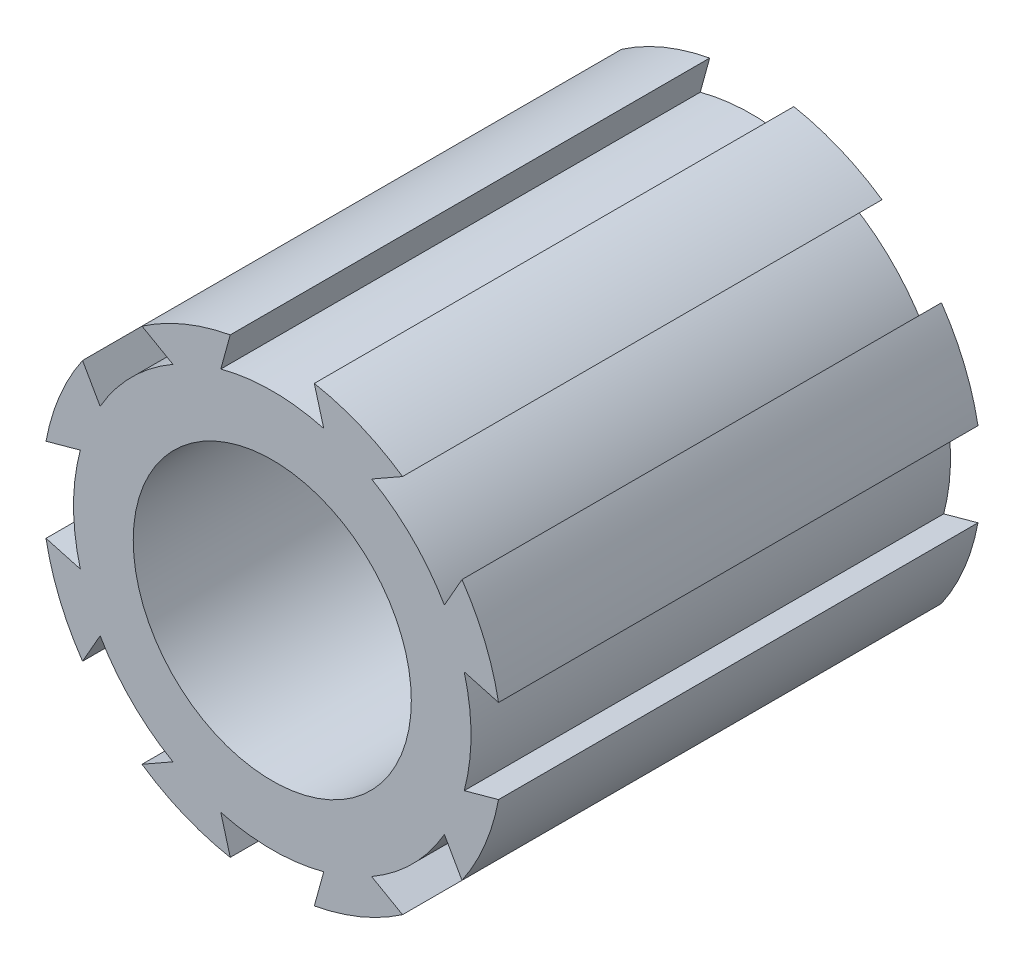
from build123d import *

# Parameters (mm, degrees)
ESQUISSE5_R                  = 24
ESQUISSE5_R_2                = 14.5
BOSS_EXTRU_2_DEPTH           = 50
ENL_V_MAT_EXTRU_4_DEPTH      = 61.431779719
ENL_V_MAT_EXTRU_4_DEPTH_BACK = 16


with BuildPart() as part:
    # Esquisse5 → Boss.-Extru.2 (new body)
    with BuildSketch(Plane.XY):
        Circle(ESQUISSE5_R)
        Circle(ESQUISSE5_R_2, mode=Mode.SUBTRACT)
    extrude(amount=BOSS_EXTRU_2_DEPTH)

    # Esquisse6 → Enlèv. mat.-Extru.4 (cut, two sides: drawn at the far end of the back side and taken through both)
    with BuildSketch(Plane.XY.offset(-ENL_V_MAT_EXTRU_4_DEPTH_BACK)):
        with BuildLine():
            Line((-4.384096163, 23.596179793), (-5.367769198, 20.017709679))
            ThreePointArc((-5.367769198, 20.017709679), (0, 20.724904028), (5.367769198, 20.017709679))
            Line((5.367769198, 20.017709679), (4.384096163, 23.596179793))
            ThreePointArc((4.384096163, 23.596179793), (0, 24), (-4.384096163, 23.596179793))
        make_face()
        with BuildLine():
            Line((19.785042868, 13.584994616), (17.950244258, 10.359072259))
            ThreePointArc((17.950244258, 10.359072259), (14.654720178, 14.654720178), (10.359072259, 17.950244258))
            Line((10.359072259, 17.950244258), (13.584994616, 19.785042868))
            ThreePointArc((13.584994616, 19.785042868), (16.970562748, 16.970562748), (19.785042868, 13.584994616))
        make_face()
        with BuildLine():
            Line((23.596179793, -4.384096163), (20.017709679, -5.367769198))
            ThreePointArc((20.017709679, -5.367769198), (20.724904028, 0), (20.017709679, 5.367769198))
            Line((20.017709679, 5.367769198), (23.596179793, 4.384096163))
            ThreePointArc((23.596179793, 4.384096163), (24, 0), (23.596179793, -4.384096163))
        make_face()
        with BuildLine():
            Line((13.584994616, -19.785042868), (10.359072259, -17.950244258))
            ThreePointArc((10.359072259, -17.950244258), (14.654720178, -14.654720178), (17.950244258, -10.359072259))
            Line((17.950244258, -10.359072259), (19.785042868, -13.584994616))
            ThreePointArc((19.785042868, -13.584994616), (16.970562748, -16.970562748), (13.584994616, -19.785042868))
        make_face()
        with BuildLine():
            Line((-4.384096163, -23.596179793), (-5.367769198, -20.017709679))
            ThreePointArc((-5.367769198, -20.017709679), (0, -20.724904028), (5.367769198, -20.017709679))
            Line((5.367769198, -20.017709679), (4.384096163, -23.596179793))
            ThreePointArc((4.384096163, -23.596179793), (0, -24), (-4.384096163, -23.596179793))
        make_face()
        with BuildLine():
            Line((-19.785042868, -13.584994616), (-17.950244258, -10.359072259))
            ThreePointArc((-17.950244258, -10.359072259), (-14.654720178, -14.654720178), (-10.359072259, -17.950244258))
            Line((-10.359072259, -17.950244258), (-13.584994616, -19.785042868))
            ThreePointArc((-13.584994616, -19.785042868), (-16.970562748, -16.970562748), (-19.785042868, -13.584994616))
        make_face()
        with BuildLine():
            Line((-23.596179793, 4.384096163), (-20.017709679, 5.367769198))
            ThreePointArc((-20.017709679, 5.367769198), (-20.724904028, 0), (-20.017709679, -5.367769198))
            Line((-20.017709679, -5.367769198), (-23.596179793, -4.384096163))
            ThreePointArc((-23.596179793, -4.384096163), (-24, 0), (-23.596179793, 4.384096163))
        make_face()
        with BuildLine():
            Line((-13.584994616, 19.785042868), (-10.359072259, 17.950244258))
            ThreePointArc((-10.359072259, 17.950244258), (-14.654720178, 14.654720178), (-17.950244258, 10.359072259))
            Line((-17.950244258, 10.359072259), (-19.785042868, 13.584994616))
            ThreePointArc((-19.785042868, 13.584994616), (-16.970562748, 16.970562748), (-13.584994616, 19.785042868))
        make_face()
    extrude(amount=ENL_V_MAT_EXTRU_4_DEPTH + ENL_V_MAT_EXTRU_4_DEPTH_BACK, mode=Mode.SUBTRACT)


solid = part.part
